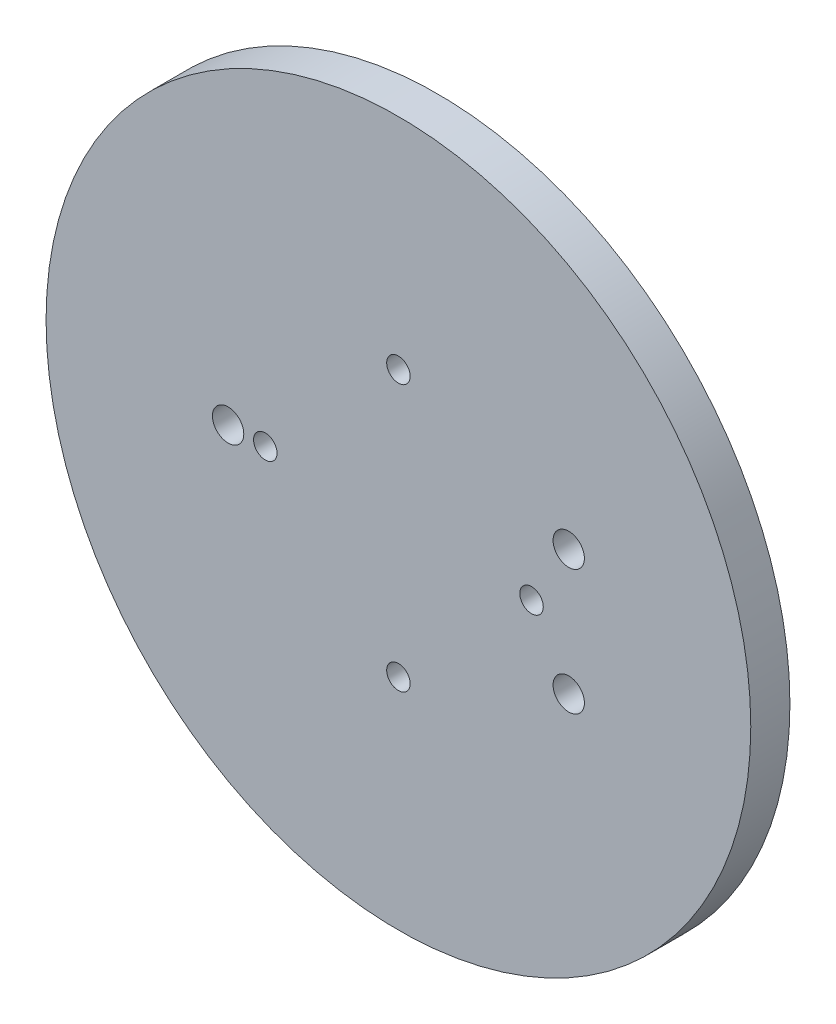
from build123d import *

# Parameters (mm, degrees)
SKETCH1_R           = 45
BOSS_EXTRUDE1_DEPTH = 5
SKETCH3_R           = 2
SKETCH3_R_2         = 1.5
CUT_EXTRUDE1_DEPTH  = 10


with BuildPart() as part:
    # Sketch1 → Boss-Extrude1 (new body)
    with BuildSketch(Plane.XY):
        Circle(SKETCH1_R)
    extrude(amount=BOSS_EXTRUDE1_DEPTH)

    # Sketch3 → Cut-Extrude1 (cut)
    with BuildSketch(Plane.XY.offset(5)):
        with Locations((-21.75, 0)):
            Circle(SKETCH3_R)
        with Locations((21.75, 8)):
            Circle(SKETCH3_R)
        with Locations((21.75, -8)):
            Circle(SKETCH3_R)
        with Locations((0, 17)):
            Circle(SKETCH3_R_2)
        with Locations((17, 0)):
            Circle(SKETCH3_R_2)
        with Locations((0, -17)):
            Circle(SKETCH3_R_2)
        with Locations((-17, 0)):
            Circle(SKETCH3_R_2)
    extrude(amount=-CUT_EXTRUDE1_DEPTH, mode=Mode.SUBTRACT)


solid = part.part
